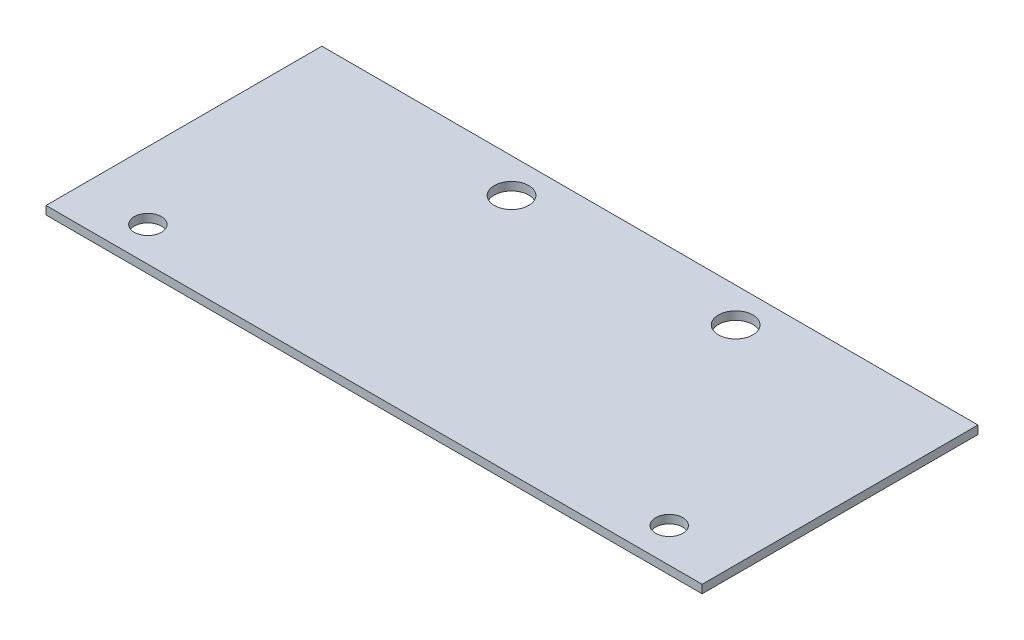
from build123d import *

# Parameters (mm, degrees)
BOSS_EXTRUDE1_DEPTH = 1.524
SKETCH2_R           = 2.5019
SKETCH2_R_2         = 3.175
CUT_EXTRUDE1_DEPTH  = 2.524


with BuildPart() as part:
    # Sketch1 → Boss-Extrude1 (new body)
    with BuildSketch(Plane(origin=(0, 0, 0), x_dir=(1, 0, 0), z_dir=(0, 1, 0))):
        Polygon((-50.221590033, -9.319139437), (70.606209967, -9.319139437), (70.606209967, 41.480860563), (35.630409967, 41.480860563), (-15.169590033, 41.480860563), (-50.221590033, 41.480860563), align=None)
    extrude(amount=BOSS_EXTRUDE1_DEPTH)

    # Sketch2 → Cut-Extrude1 (cut, through all)
    with BuildSketch(Plane(origin=(0, 1.524, 0), x_dir=(1, 0, 0), z_dir=(0, 1, 0))):
        with Locations((-37.813690033, -2.969139437)):
            Circle(SKETCH2_R)
        with Locations((58.198309967, -2.969139437)):
            Circle(SKETCH2_R)
        with Locations((32.328409967, 35.130860563)):
            Circle(SKETCH2_R_2)
        with Locations((-8.946590033, 35.130860563)):
            Circle(SKETCH2_R_2)
    extrude(amount=-CUT_EXTRUDE1_DEPTH, mode=Mode.SUBTRACT)


solid = part.part
